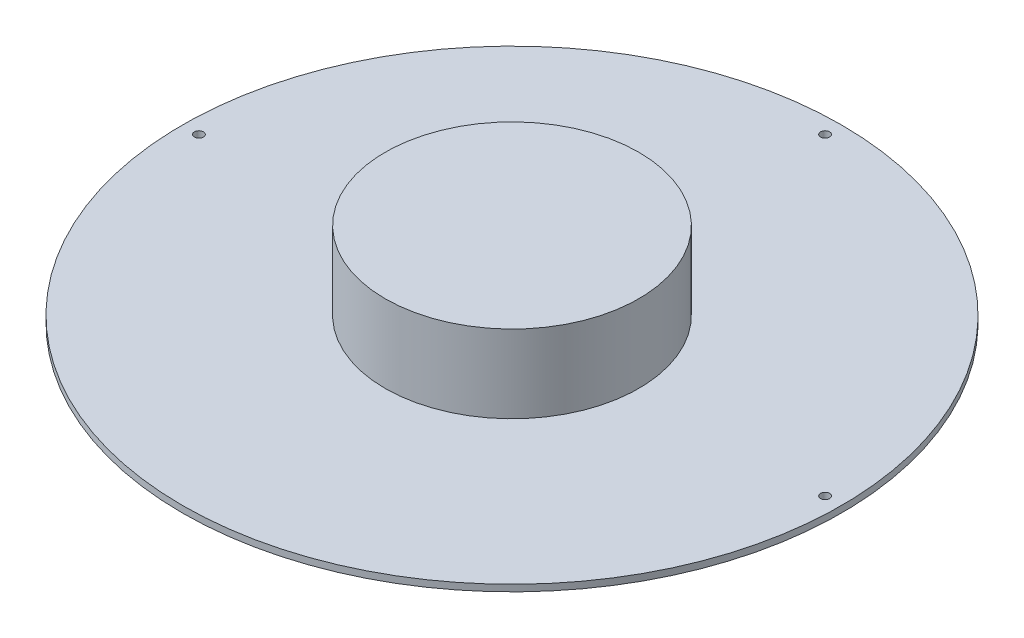
from build123d import *

# Parameters (mm, degrees)
SKETCH1_R                = 80
BOSS_EXTRUDE1_DEPTH      = 1.6
SKETCH2_R                = 2.3
CUT_EXTRUDE1_DEPTH       = 1.6
M2_CLEARANCE_HOLE2_D     = 2.2
M2_CLEARANCE_HOLE2_DEPTH = 6
M2_CLEARANCE_HOLE2_TIP   = 0.660946681
SKETCH9_R                = 30.8
BOSS_EXTRUDE2_DEPTH      = 18.86
SKETCH10_R               = 1.5
BOSS_EXTRUDE3_DEPTH      = 4
SKETCH11_R               = 0.7
BOSS_EXTRUDE4_DEPTH      = 3.8


with BuildPart() as part:
    # Sketch1 → Boss-Extrude1 (new body)
    with BuildSketch(Plane(origin=(0, 0, 0), x_dir=(1, 0, 0), z_dir=(0, 1, 0))):
        Circle(SKETCH1_R)
    extrude(amount=BOSS_EXTRUDE1_DEPTH)

    # Sketch2 → Cut-Extrude1 (cut)
    with BuildSketch(Plane(origin=(0, 1.6, 0), x_dir=(1, 0, 0), z_dir=(0, 1, 0))):
        Circle(SKETCH2_R)
    extrude(amount=-CUT_EXTRUDE1_DEPTH, mode=Mode.SUBTRACT)

    # M2 Clearance Hole2
    with Locations(Plane(origin=(0, 1.6, 0), x_dir=(1, 0, 0), z_dir=(0, 1, 0))):
        with Locations((0, 76), (76, 0), (-76, 0)):
            Hole(M2_CLEARANCE_HOLE2_D / 2, depth=M2_CLEARANCE_HOLE2_DEPTH)
            with Locations((0, 0, -(M2_CLEARANCE_HOLE2_DEPTH + M2_CLEARANCE_HOLE2_TIP / 2))):  # 118° drill point
                Cone(0, M2_CLEARANCE_HOLE2_D / 2, M2_CLEARANCE_HOLE2_TIP, mode=Mode.SUBTRACT)

    # Sketch9 → Boss-Extrude2 (add)
    with BuildSketch(Plane(origin=(0, 1.6, 0), x_dir=(1, 0, 0), z_dir=(0, 1, 0))):
        Circle(SKETCH9_R)
    extrude(amount=BOSS_EXTRUDE2_DEPTH)

    # Sketch10 → Boss-Extrude3 (add)
    with BuildSketch(Plane.XZ.offset(-1.6)):
        Circle(SKETCH10_R)
    extrude(amount=BOSS_EXTRUDE3_DEPTH)

    # Sketch11 → Boss-Extrude4 (add)
    with BuildSketch(Plane.XZ.offset(2.4)):
        Circle(SKETCH11_R)
    extrude(amount=BOSS_EXTRUDE4_DEPTH)


solid = part.part
